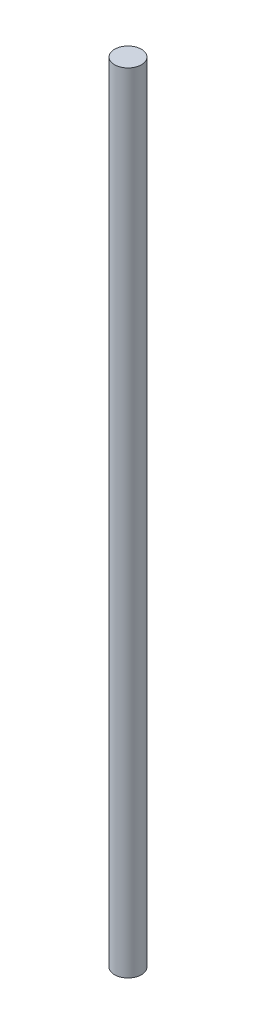
from build123d import *

# Parameters (mm, degrees)
SKETCH1_R           = 9.525
BOSS_EXTRUDE1_DEPTH = 558.8


with BuildPart() as part:
    # Sketch1 → Boss-Extrude1 (new body)
    with BuildSketch(Plane(origin=(0, 0, 0), x_dir=(1, 0, 0), z_dir=(0, 1, 0))):
        Circle(SKETCH1_R)
    extrude(amount=BOSS_EXTRUDE1_DEPTH)


solid = part.part
